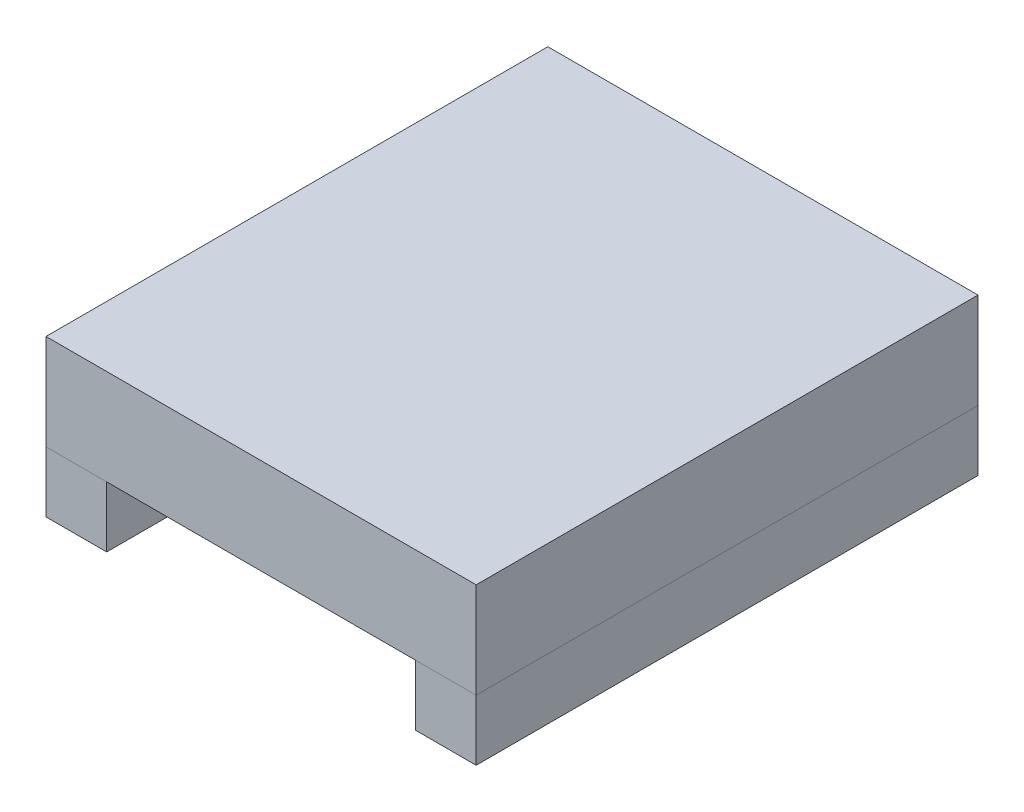
from build123d import *

# Parameters (mm, degrees)
SKETCH_1_W        = 18
SKETCH_1_H        = 21
EXTRUDE_1_DEPTH   = 4
SKETCH_2_W        = 2.54
SKETCH_2_H        = 21
EXTRUDE_2_DEPTH   = 2.54
EXTRUDE_2_2_DEPTH = 2.54


with BuildPart() as part:
    # Эскиз1 → Бобышка-Вытянуть1 (new body)
    with BuildSketch(Plane(origin=(0, 0, 0), x_dir=(1, 0, 0), z_dir=(0, 1, 0))):
        Rectangle(SKETCH_1_W, SKETCH_1_H)
    extrude(amount=EXTRUDE_1_DEPTH)


with BuildPart() as body_2:
    # Эскиз2 → Бобышка-Вытянуть2 (new body)
    with BuildSketch(Plane.XZ):
        with Locations((7.73, 0)):
            Rectangle(SKETCH_2_W, SKETCH_2_H)
    extrude(amount=EXTRUDE_2_DEPTH)


with BuildPart() as body_3:
    # Эскиз2 → Extrude 2 2 (new body)
    with BuildSketch(Plane.XZ):
        with Locations((-7.73, 0)):
            Rectangle(SKETCH_2_W, SKETCH_2_H)
    extrude(amount=EXTRUDE_2_2_DEPTH)


solid = Compound([part.part, body_2.part, body_3.part])
